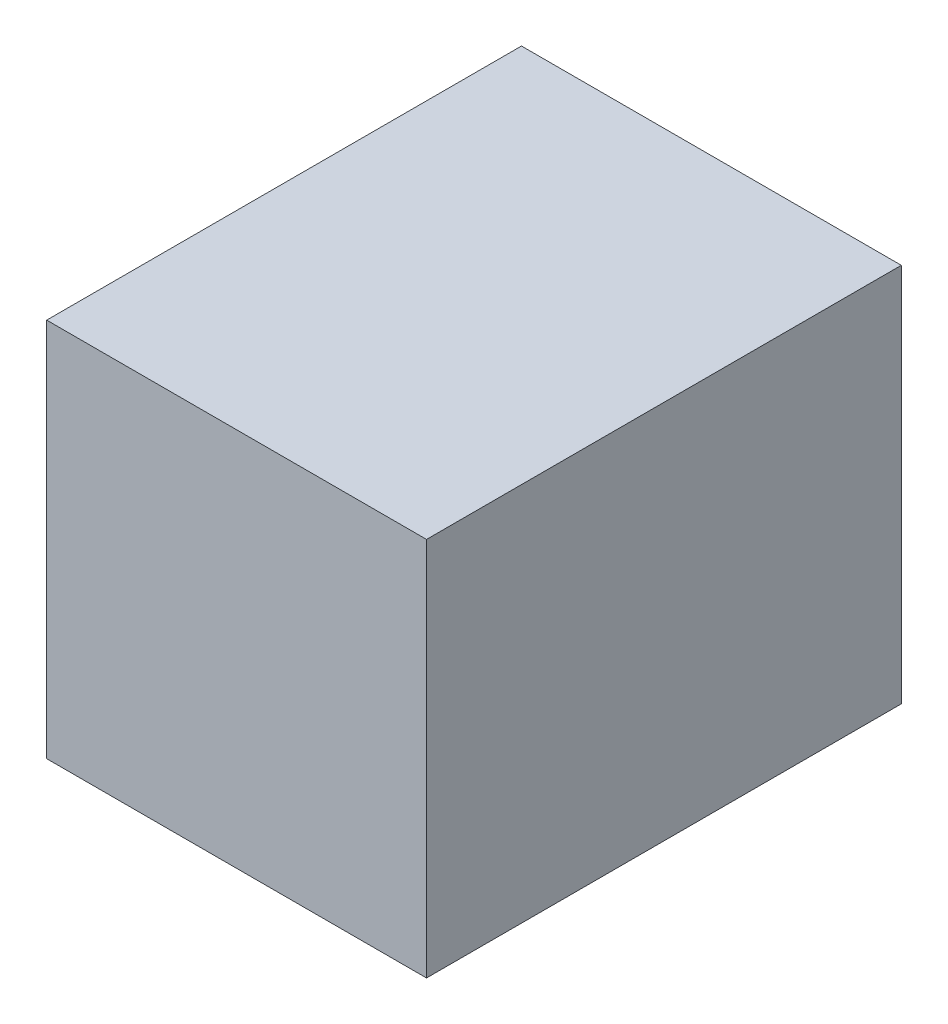
from build123d import *

# Parameters (mm, degrees)
SKETCH2_W           = 16
SKETCH2_H           = 16
BOSS_EXTRUDE1_DEPTH = 20
SKETCH3_R           = 2
BOSS_EXTRUDE2_DEPTH = 6


with BuildPart() as part:
    # Sketch2 → Boss-Extrude1 (new body)
    with BuildSketch(Plane.XY):
        Rectangle(SKETCH2_W, SKETCH2_H)
    extrude(amount=BOSS_EXTRUDE1_DEPTH)

    # Sketch3 → Boss-Extrude2 (add)
    with BuildSketch(Plane.ZY.offset(8)):
        with Locations((10, 0)):
            Circle(SKETCH3_R)
    extrude(amount=BOSS_EXTRUDE2_DEPTH)


solid = part.part
